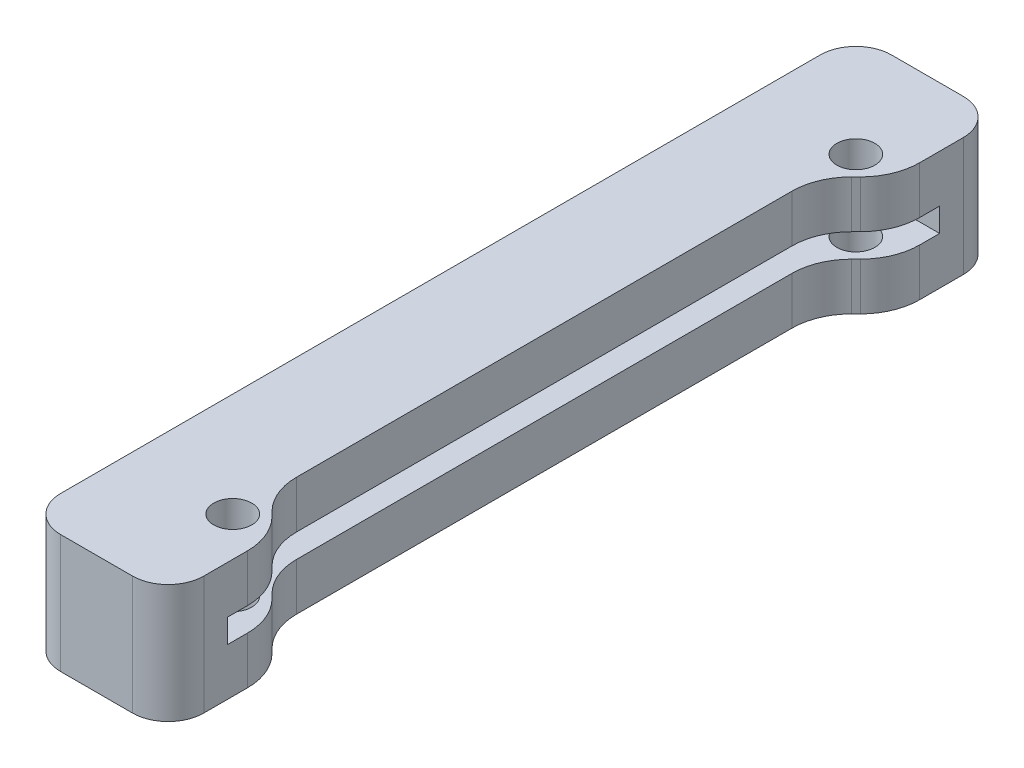
from build123d import *

# Parameters (mm, degrees)
SKETCH3_R           = 1.6
BOSS_EXTRUDE1_DEPTH = 5
SKETCH4_W           = 13.182571809
SKETCH4_H           = 60
CUT_EXTRUDE1_DEPTH  = 1
FILLET1_R           = 5
FILLET2_R           = 3


with BuildPart() as part:
    # Sketch3 → Boss-Extrude1 (new body, symmetric)
    with BuildSketch(Plane(origin=(0, 0, 0), x_dir=(1, 0, 0), z_dir=(0, 1, 0))):
        Polygon((-81.692561237, 30), (-81.692561237, 26.25), (-85, 22.942561237), (-85, -22.942561237), (-81.692561237, -26.25), (-81.692561237, -30), (-81.692561237, -35), (-93.75, -35), (-93.75, 35), (-81.692561237, 35), align=None)
        with Locations((-85, 26.25)):
            Circle(SKETCH3_R, mode=Mode.SUBTRACT)
        with Locations((-85, -26.25)):
            Circle(SKETCH3_R, mode=Mode.SUBTRACT)
    extrude(amount=BOSS_EXTRUDE1_DEPTH, both=True)

    # Sketch4 → Cut-Extrude1 (cut, symmetric)
    with BuildSketch(Plane(origin=(0, 0, 0), x_dir=(1, 0, 0), z_dir=(0, 1, 0))):
        with Locations((-82.158714096, 0)):
            Rectangle(SKETCH4_W, SKETCH4_H)
    extrude(amount=CUT_EXTRUDE1_DEPTH, both=True, mode=Mode.SUBTRACT)

    # Fillet1
    fillet1_edges = [part.edges().sort_by_distance(p)[0] for p in [
        (-81.692561237, 3, -26.25),
        (-85, 3, -22.942561237),
        (-85, 3, 22.942561237),
        (-81.692561237, 3, 26.25),
        (-81.692561237, -3, -26.25),
        (-85, -3, -22.942561237),
        (-85, -3, 22.942561237),
        (-81.692561237, -3, 26.25),
    ]]
    fillet(fillet1_edges, radius=FILLET1_R)

    # Fillet2
    fillet2_edges = [part.edges().sort_by_distance(p)[0] for p in [
        (-81.692561237, 0, 35),
        (-93.75, 0, 35),
        (-93.75, 0, -35),
        (-81.692561237, 0, -35),
    ]]
    fillet(fillet2_edges, radius=FILLET2_R)


solid = part.part
